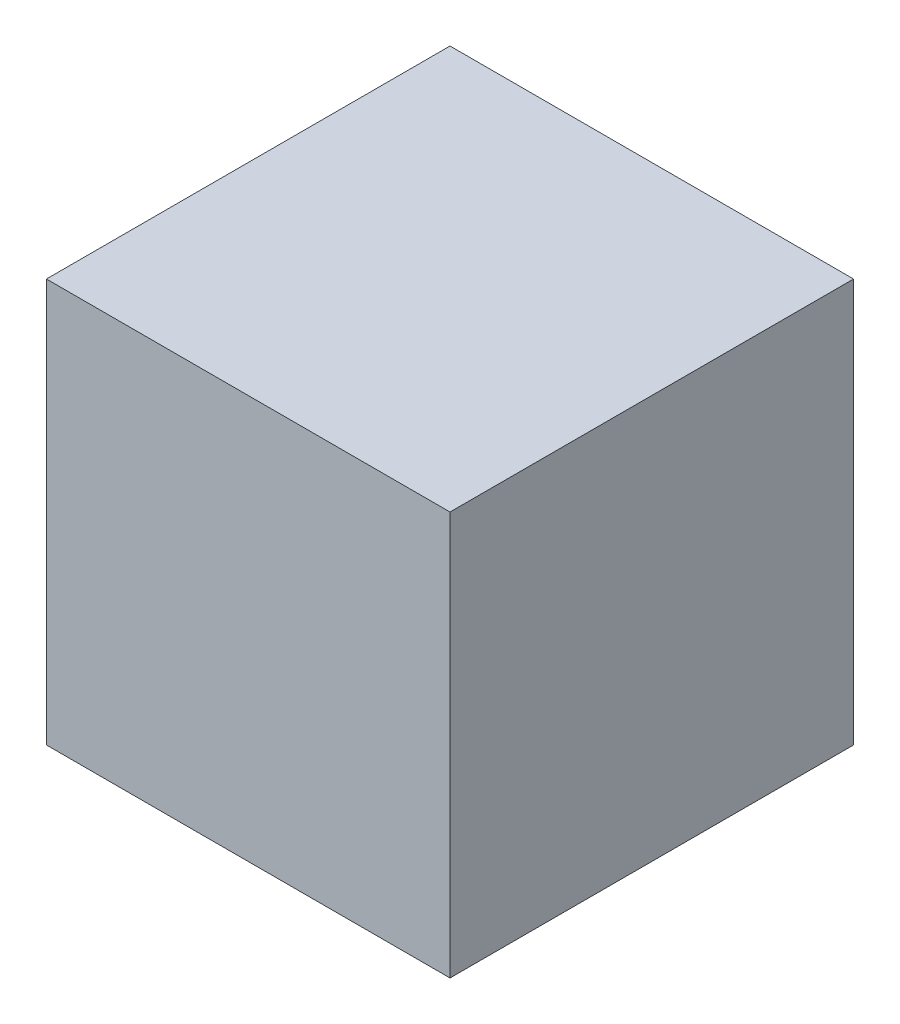
from build123d import *

# Parameters (mm, degrees)
SKETCH2_W           = 10
SKETCH2_H           = 10
BOSS_EXTRUDE2_DEPTH = 10


with BuildPart() as part:
    # Sketch2 → Boss-Extrude2 (new body)
    with BuildSketch(Plane.XY):
        with Locations((5, 5)):
            Rectangle(SKETCH2_W, SKETCH2_H)
    extrude(amount=BOSS_EXTRUDE2_DEPTH)


solid = part.part
